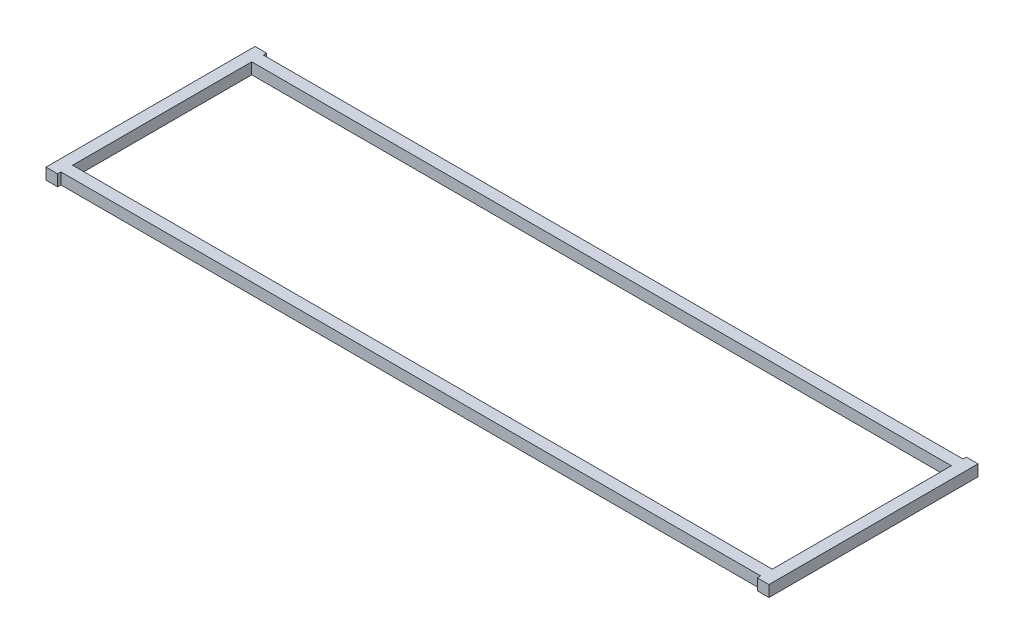
from build123d import *

# Parameters (mm, degrees)
SKETCH1_W           = 393.7
SKETCH1_H           = 100.9392952
BOSS_EXTRUDE1_DEPTH = 6.35
SKETCH2_W           = 393.4968
SKETCH2_H           = 100.7360952
BOSS_EXTRUDE2_DEPTH = 6.35


with BuildPart() as part:
    # Sketch1 → Boss-Extrude1 (new body)
    with BuildSketch(Plane(origin=(0, 0, 0), x_dir=(1, 0, 0), z_dir=(0, 1, 0))):
        Polygon((196.85, 58.683525), (203.2, 58.683525), (203.2, -58.683525), (196.85, -58.683525), (196.85, -56.8196476), (-196.85, -56.8196476), (-196.85, -58.683525), (-203.2, -58.683525), (-203.2, 58.683525), (-196.85, 58.683525), (-196.85, 56.8196476), (196.85, 56.8196476), align=None)
        Rectangle(SKETCH1_W, SKETCH1_H, mode=Mode.SUBTRACT)
    extrude(amount=BOSS_EXTRUDE1_DEPTH)

    # Sketch2 → Boss-Extrude2 (add)
    with BuildSketch(Plane(origin=(0, 6.35, 0), x_dir=(1, 0, 0), z_dir=(0, 1, 0))):
        Polygon((196.7484, -58.785125), (203.3016, -58.785125), (203.3016, 58.785125), (196.7484, 58.785125), (196.7484, 56.9212476), (-196.7484, 56.9212476), (-196.7484, 58.785125), (-203.3016, 58.785125), (-203.3016, -58.785125), (-196.7484, -58.785125), (-196.7484, -56.9212476), (196.7484, -56.9212476), align=None)
        Rectangle(SKETCH2_W, SKETCH2_H, mode=Mode.SUBTRACT)
    extrude(amount=-BOSS_EXTRUDE2_DEPTH)


solid = part.part
